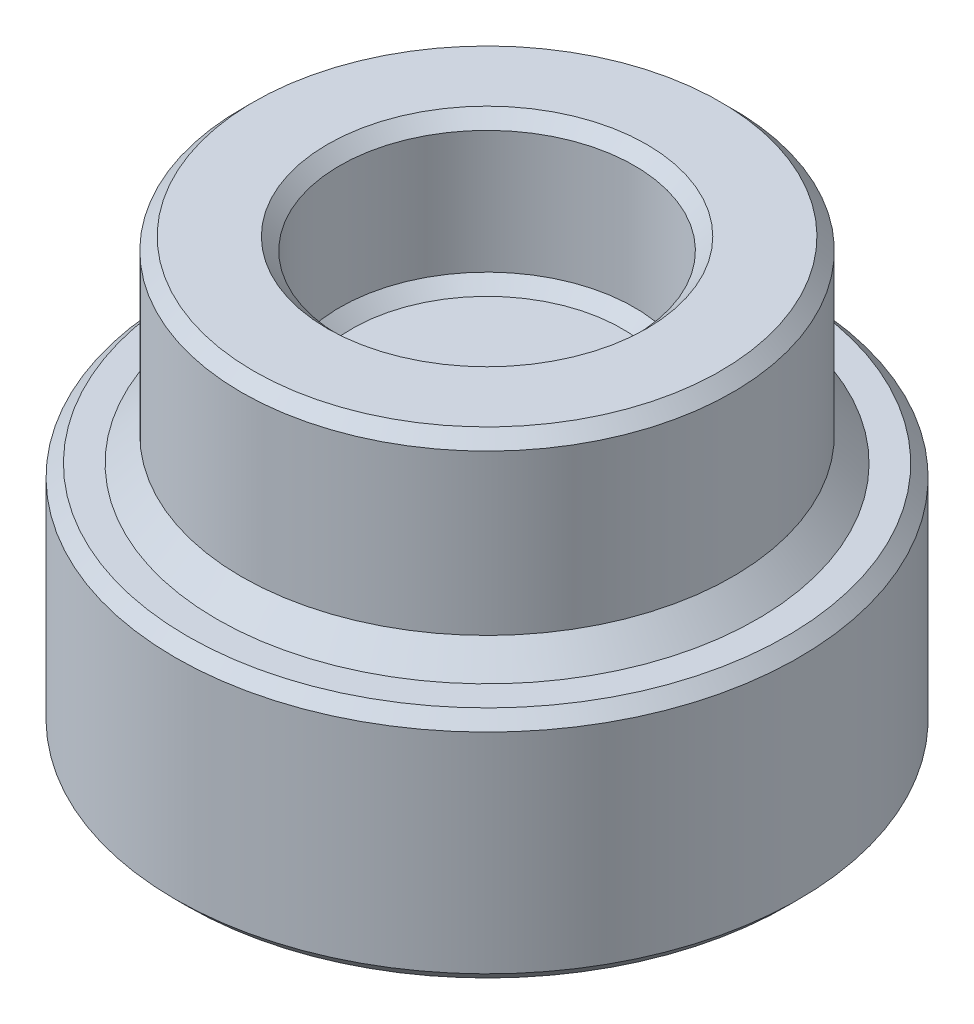
from build123d import *

# Parameters (mm, degrees)
SKETCH1_R                                = 5
BOSS_EXTRUDE1_DEPTH                      = 1
SKETCH1_3_R                              = 5
SKETCH1_3_R_2                            = 3
BOSS_EXTRUDE2_DEPTH                      = 4
CHAMFER1_SIZE                            = 0.25
SKETCH5_R                                = 6.35
BOSS_EXTRUDE4_DEPTH                      = 4.7625
F_5_16_0_3125_DIAMETER_HOLE1_D           = 7.9375
F_5_16_0_3125_DIAMETER_HOLE1_DEPTH       = 4.415279367
F_5_16_0_3125_DIAMETER_HOLE1_CSINK_D     = 8.1915
F_5_16_0_3125_DIAMETER_HOLE1_CSINK_ANGLE = 90
F_5_16_0_3125_DIAMETER_HOLE1_TIP         = 0.347220633
CHAMFER2_SIZE                            = 0.25
CHAMFER3_SIZE                            = 0.5


with BuildPart() as part:
    # Sketch1 → Boss-Extrude1 (new body)
    with BuildSketch(Plane(origin=(0, 0, 0), x_dir=(1, 0, 0), z_dir=(0, 1, 0))):
        Circle(SKETCH1_R)
    extrude(amount=BOSS_EXTRUDE1_DEPTH)

    # Sketch1_3 → Boss-Extrude2 (add)
    with BuildSketch(Plane(origin=(0, 0, 0), x_dir=(1, 0, 0), z_dir=(0, 1, 0))):
        Circle(SKETCH1_3_R)
        Circle(SKETCH1_3_R_2, mode=Mode.SUBTRACT)
    extrude(amount=BOSS_EXTRUDE2_DEPTH)

    # Chamfer1
    chamfer1_edges = [part.edges().sort_by_distance(p)[0] for p in [
        (-3, 4, 0),
        (-5, 4, 0),
        (-3, 1, 0),
    ]]
    chamfer(chamfer1_edges, length=CHAMFER1_SIZE)

    # Sketch5 → Boss-Extrude4 (add)
    with BuildSketch(Plane(origin=(0, 0, 0), x_dir=(1, 0, 0), z_dir=(0, 1, 0))):
        Circle(SKETCH5_R)
    extrude(amount=-BOSS_EXTRUDE4_DEPTH)

    # 5_16 _0.3125_ Diameter Hole1
    with Locations(Plane(origin=(0, -4.7625, 0), x_dir=(-1, 0, 0), z_dir=(0, -1, 0))):
        with Locations((0, 0)):
            CounterSinkHole(F_5_16_0_3125_DIAMETER_HOLE1_D / 2, F_5_16_0_3125_DIAMETER_HOLE1_CSINK_D / 2, depth=F_5_16_0_3125_DIAMETER_HOLE1_DEPTH, counter_sink_angle=F_5_16_0_3125_DIAMETER_HOLE1_CSINK_ANGLE)
            with Locations((0, 0, -(F_5_16_0_3125_DIAMETER_HOLE1_DEPTH + F_5_16_0_3125_DIAMETER_HOLE1_TIP / 2))):  # 170° drill point
                Cone(0, F_5_16_0_3125_DIAMETER_HOLE1_D / 2, F_5_16_0_3125_DIAMETER_HOLE1_TIP, mode=Mode.SUBTRACT)

    # Chamfer2
    chamfer2_edges = [part.edges().sort_by_distance(p)[0] for p in [
        (-6.35, -4.7625, 0),
        (-6.35, 0, 0),
    ]]
    chamfer(chamfer2_edges, length=CHAMFER2_SIZE)

    # Chamfer3
    chamfer3_edges = [part.edges().sort_by_distance(p)[0] for p in [
        (-5, 0, 0),
    ]]
    chamfer(chamfer3_edges, length=CHAMFER3_SIZE)


solid = part.part
